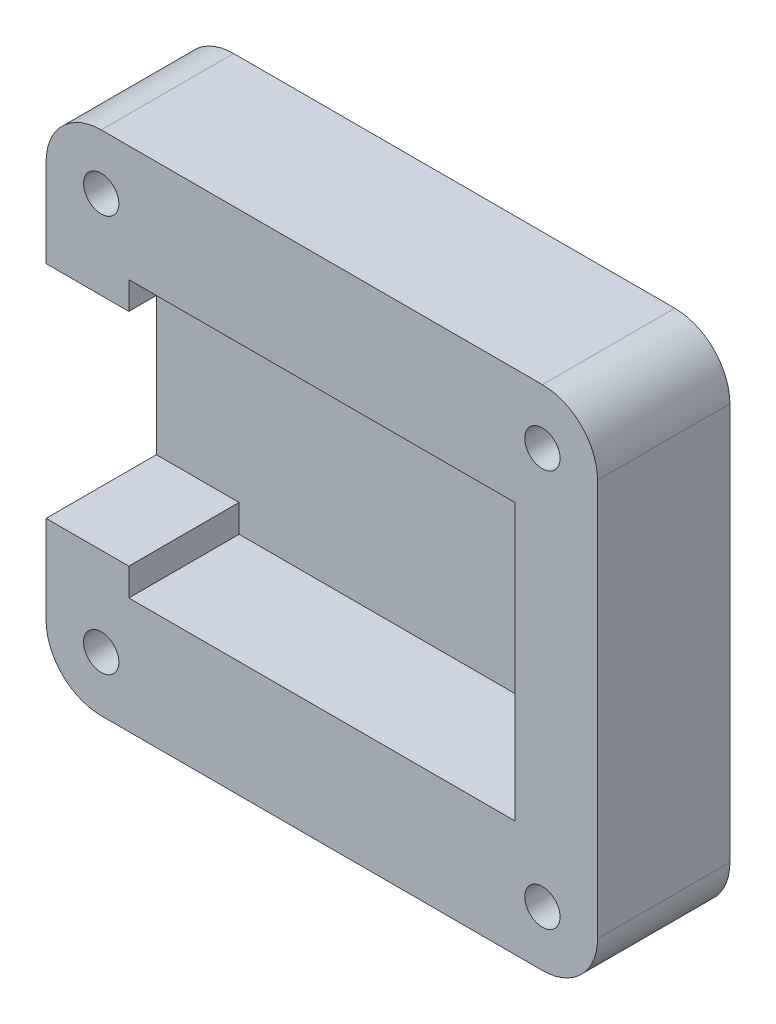
from build123d import *

# Parameters (mm, degrees)
SKIZZE1_W                                            = 25
SKIZZE1_H                                            = 23
AUFSATZ_LINEAR_AUSTRAGEN1_DEPTH                      = 6
SKIZZE1_3_W                                          = 17.5
SKIZZE1_3_H                                          = 12.5
SCHNITT_LINEAR_AUSTRAGEN1_DEPTH                      = 5
SKIZZE2_W                                            = 3.75
SKIZZE2_H                                            = 10
SCHNITT_LINEAR_AUSTRAGEN2_DEPTH                      = 5
FORMSENKUNG_F_R_M3_SENKSCHRAUBE_MIT_INNE_D           = 1.6
FORMSENKUNG_F_R_M3_SENKSCHRAUBE_MIT_INNE_CSINK_D     = 3.5
FORMSENKUNG_F_R_M3_SENKSCHRAUBE_MIT_INNE_CSINK_ANGLE = 90
VERRUNDUNG1_R                                        = 2.5


with BuildPart() as part:
    # Skizze1 → Aufsatz-Linear austragen1 (new body)
    with BuildSketch(Plane.XY):
        Rectangle(SKIZZE1_W, SKIZZE1_H)
    extrude(amount=-AUFSATZ_LINEAR_AUSTRAGEN1_DEPTH)

    # Skizze1_3 → Schnitt-Linear austragen1 (cut)
    with BuildSketch(Plane.XY):
        Rectangle(SKIZZE1_3_W, SKIZZE1_3_H)
    extrude(amount=-SCHNITT_LINEAR_AUSTRAGEN1_DEPTH, mode=Mode.SUBTRACT)

    # Skizze2 → Schnitt-Linear austragen2 (cut)
    with BuildSketch(Plane.XY):
        with Locations((-10.625, 0)):
            Rectangle(SKIZZE2_W, SKIZZE2_H)
    extrude(amount=-SCHNITT_LINEAR_AUSTRAGEN2_DEPTH, mode=Mode.SUBTRACT)

    # Formsenkung für M3 Senkschraube mit Innensechskant1 (through all)
    with Locations(Plane(origin=(0, 0, -6), x_dir=(-1, 0, 0), z_dir=(0, 0, -1))):
        with Locations((-10, 9), (10, 9), (10, -9), (-10, -9)):
            CounterSinkHole(FORMSENKUNG_F_R_M3_SENKSCHRAUBE_MIT_INNE_D / 2, FORMSENKUNG_F_R_M3_SENKSCHRAUBE_MIT_INNE_CSINK_D / 2, counter_sink_angle=FORMSENKUNG_F_R_M3_SENKSCHRAUBE_MIT_INNE_CSINK_ANGLE)

    # Verrundung1
    verrundung1_edges = [part.edges().sort_by_distance(p)[0] for p in [
        (-12.5, 11.5, -3),
        (12.5, 11.5, -3),
        (12.5, -11.5, -3),
        (-12.5, -11.5, -3),
    ]]
    fillet(verrundung1_edges, radius=VERRUNDUNG1_R)


solid = part.part
